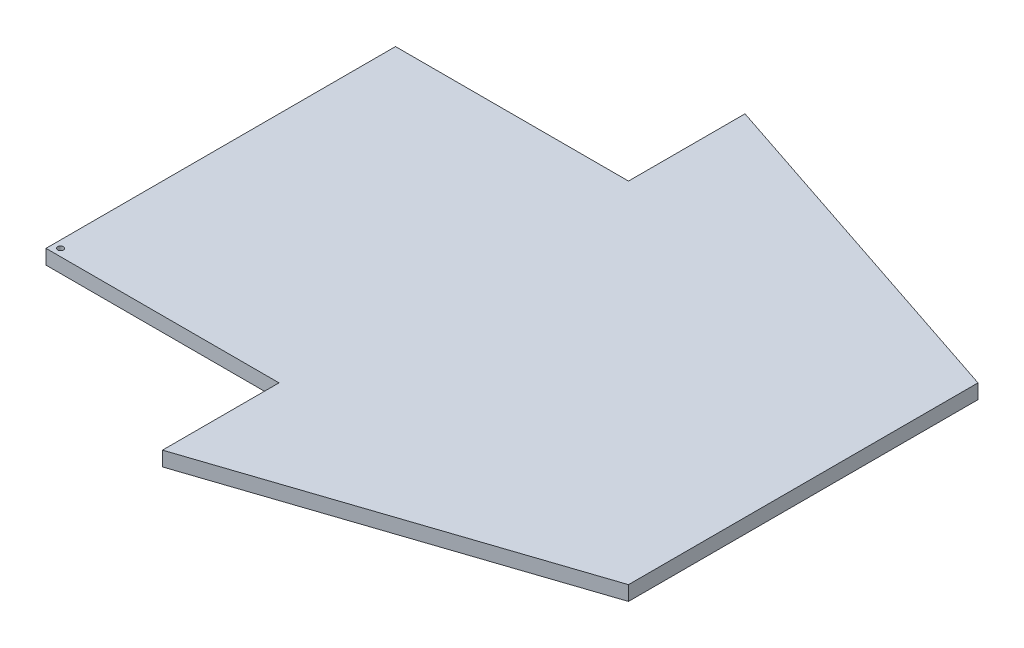
from build123d import *

# Parameters (mm, degrees)
MAIN_FIN_DEPTH = 6.35
SKETCH2_R      = 1.27
PIN_HOLE_DEPTH = 7.35


with BuildPart() as part:
    # Sketch1 → Main fin (new body)
    with BuildSketch(Plane(origin=(0, 0, 0), x_dir=(1, 0, 0), z_dir=(0, 1, 0))):
        Polygon((0, 254), (152.4, 203.2), (152.4, 50.8), (0, 0), (0, 50.8), (-101.6, 50.8), (-101.6, 203.2), (0, 203.2), align=None)
    extrude(amount=MAIN_FIN_DEPTH)

    # Sketch2 → Pin hole (cut, through all)
    with BuildSketch(Plane(origin=(0, 0, 0), x_dir=(-1, 0, 0), z_dir=(0, -1, 0))):
        with Locations((98.425, 53.975)):
            Circle(SKETCH2_R)
    extrude(amount=-PIN_HOLE_DEPTH, mode=Mode.SUBTRACT)


solid = part.part
